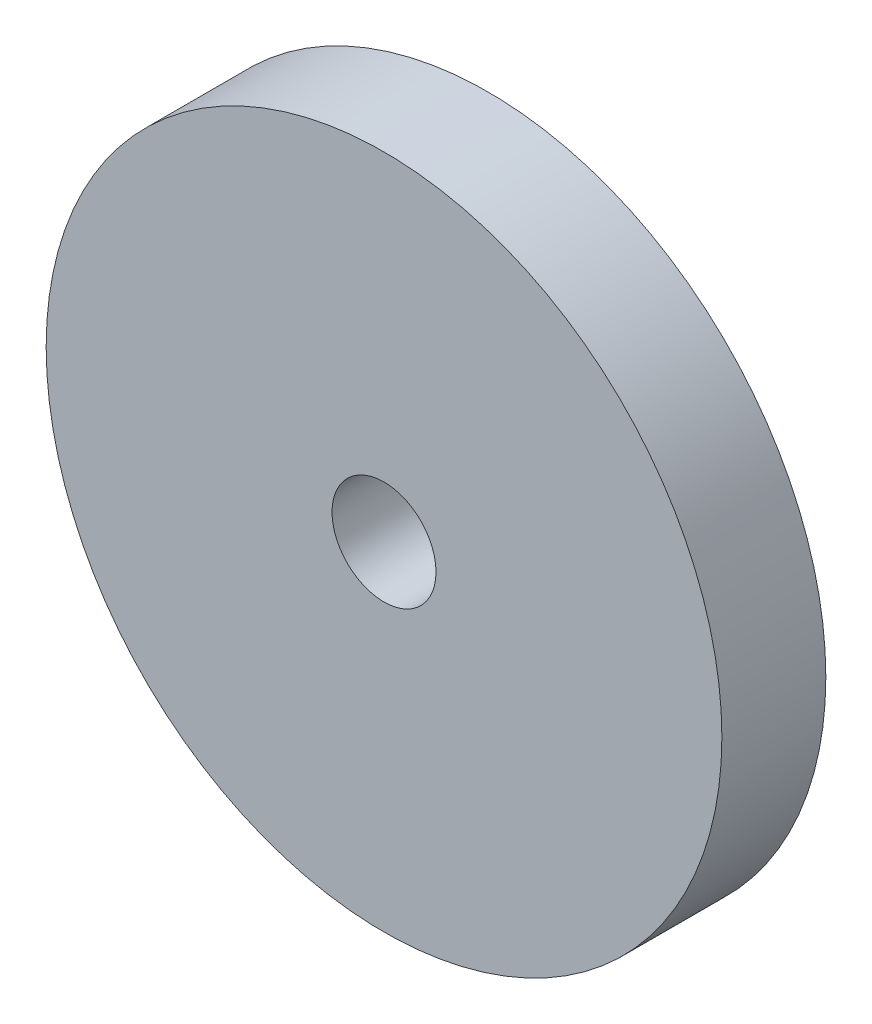
from build123d import *

# Parameters (mm, degrees)
SKETCH1_R           = 41.275
SKETCH1_R_2         = 6.35
BOSS_EXTRUDE1_DEPTH = 6.35


with BuildPart() as part:
    # Sketch1 → Boss-Extrude1 (new body, symmetric)
    with BuildSketch(Plane.XY):
        Circle(SKETCH1_R)
        Circle(SKETCH1_R_2, mode=Mode.SUBTRACT)
    extrude(amount=BOSS_EXTRUDE1_DEPTH, both=True)


solid = part.part
